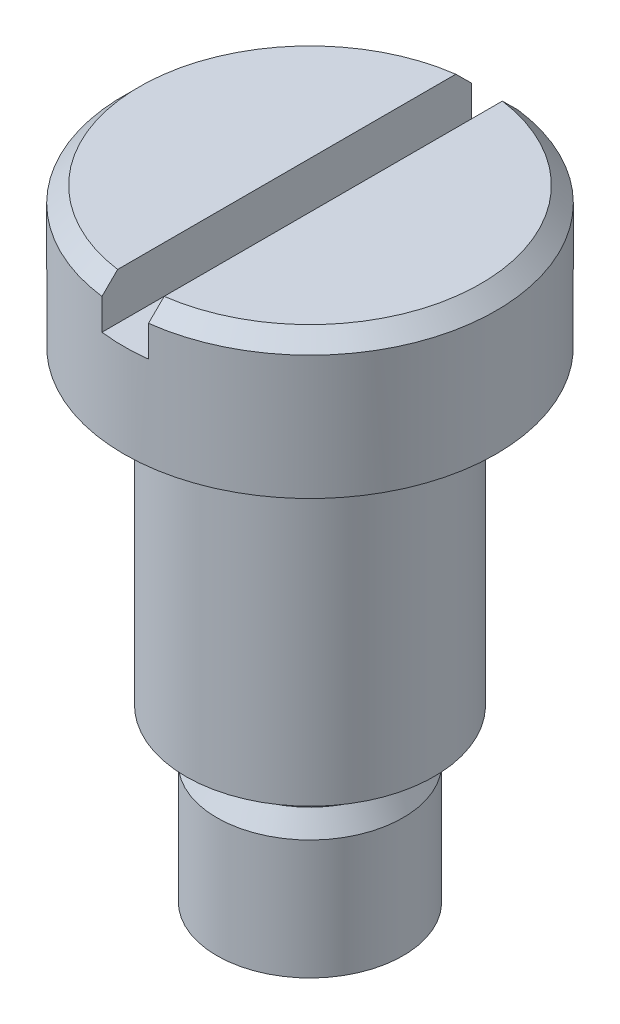
from build123d import *

# Parameters (mm, degrees)
SKETCH2_W               = 3
SKETCH2_H               = 3
CUT_EXTRUDE1_DEPTH      = 13
CUT_EXTRUDE1_DEPTH_BACK = 13
CHAMFER1_SIZE           = 1


with BuildPart() as part:
    # Sketch1 → Revolve1 (revolve)
    with BuildSketch(Plane.XY):
        Polygon((0, 40), (12, 40), (12, 31), (8, 31), (8, 11), (5.25, 11), (5.25, 9), (6, 7.700961894), (6, 0), (0, 0), align=None)
    revolve(axis=Axis((0, 0, 0), (0, 1, 0)))

    # Sketch2 → Cut-Extrude1 (cut, two sides)
    with BuildSketch(Plane.XY) as cut_extrude1_sk:
        with Locations((0, 38.5)):
            Rectangle(SKETCH2_W, SKETCH2_H)
    extrude(amount=CUT_EXTRUDE1_DEPTH, mode=Mode.SUBTRACT)
    extrude(cut_extrude1_sk.sketch, amount=-CUT_EXTRUDE1_DEPTH_BACK, mode=Mode.SUBTRACT)

    # Chamfer1
    chamfer1_edges = [part.edges().sort_by_distance(p)[0] for p in [
        (9, 40, -7.937253933),
        (-12, 40, 0),
    ]]
    chamfer(chamfer1_edges, length=CHAMFER1_SIZE)


solid = part.part
